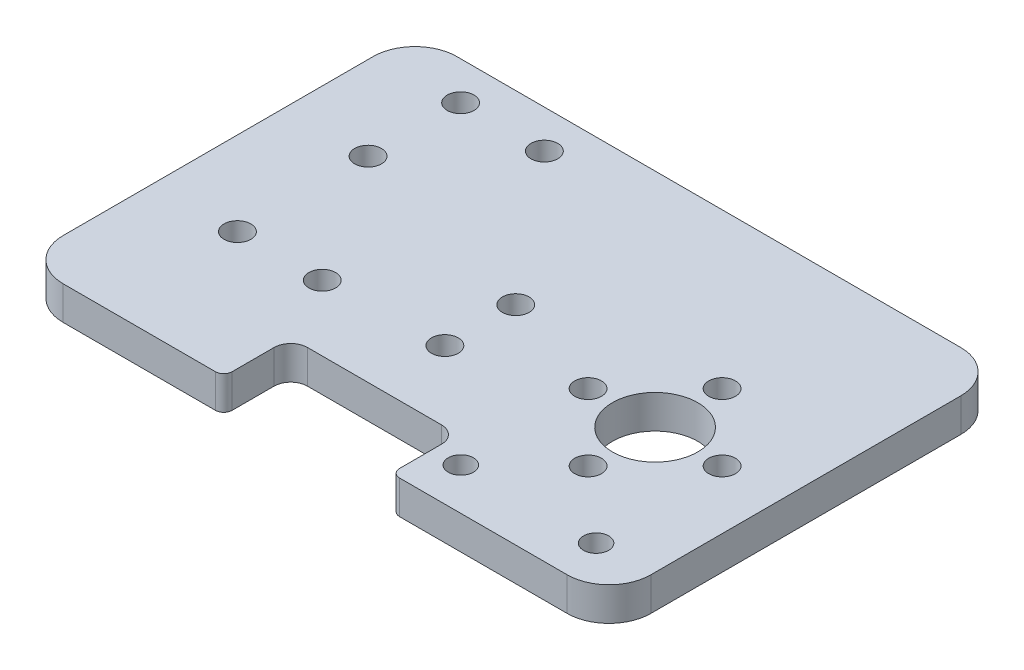
from build123d import *

# Parameters (mm, degrees)
SKETCH_1_W                = 180
SKETCH_1_H                = 43
EXTRUDE_335_DEPTH         = 4
SKETCH_2_R                = 5.1
SKETCH_2_R_2              = 1.6
CUT_EXTRUDE_616_DEPTH     = 5
SKETCH_10_W               = 20
SKETCH_10_H               = 43
CUT_EXTRUDE_3591_DEPTH    = 5
SKETCH_11_W               = 18
SKETCH_11_H               = 43
EXTRUDE_3904_DEPTH        = 4
SKETCH_12_W               = 40
SKETCH_12_H               = 13
CUT_EXTRUDE_3_DEPTH       = 10
SKETCH_14_R               = 1.6
CUT_EXTRUDE_4861_DEPTH    = 10
SKETCH_15_R               = 1.6
CUT_EXTRUDE_5298_DEPTH    = 5
PATTERN_LINEAR_5588_COUNT = 2
PATTERN_LINEAR_5588_PITCH = 29.8
CUT_EXTRUDE_6381_DEPTH    = 5
SKETCH_19_W               = 104
SKETCH_19_H               = 43
CUT_EXTRUDE_7034_DEPTH    = 5
FILLET_9_R                = 5
CUT_EXTRUDE_1_DEPTH       = 5
SKETCH_30_W               = 2
SKETCH_30_H               = 43
EXTRUDE_1_DEPTH           = 4
SKETCH_32_W               = 9
SKETCH_32_H               = 43
EXTRUDE_2_DEPTH           = 4
FILLET_11_R               = 5
EXTRUDE_3_DEPTH           = 4
FILLET_12_R               = 5
SKETCH_34_R               = 1.500000001
SKETCH_34_R_2             = 1.500000004
CUT_EXTRUDE_3_2_DEPTH     = 5
SKETCH_35_R               = 1.6
CUT_EXTRUDE_4_DEPTH       = 5
SKETCH_36_R               = 1.6
CUT_EXTRUDE_5_DEPTH       = 5
SKETCH_37_R               = 1.6
CUT_EXTRUDE_6_DEPTH       = 5
CUT_EXTRUDE_7_DEPTH       = 5
FILLET_15_R               = 1


with BuildPart() as part:
    # 草图1 → Extrude 335 (new body)
    with BuildSketch(Plane(origin=(0, 0, 0), x_dir=(1, 0, 0), z_dir=(0, 1, 0))):
        Rectangle(SKETCH_1_W, SKETCH_1_H)
    extrude(amount=EXTRUDE_335_DEPTH)

    # 草图2 → Cut-Extrude 616 (cut, through all)
    with BuildSketch(Plane(origin=(0, 4, 0), x_dir=(1, 0, 0), z_dir=(0, 1, 0))):
        with Locations((55, -5)):
            Circle(SKETCH_2_R)
        with Locations((63, -5)):
            Circle(SKETCH_2_R_2)
        with Locations((55, -13)):
            Circle(SKETCH_2_R_2)
        with Locations((47, -5)):
            Circle(SKETCH_2_R_2)
        with Locations((55, 3)):
            Circle(SKETCH_2_R_2)
    extrude(amount=-CUT_EXTRUDE_616_DEPTH, mode=Mode.SUBTRACT)

    # 草图10 → Cut-Extrude 3591 (cut, through all)
    with BuildSketch(Plane(origin=(0, 4, 0), x_dir=(1, 0, 0), z_dir=(0, 1, 0))):
        with Locations((80, 0)):
            Rectangle(SKETCH_10_W, SKETCH_10_H)
    extrude(amount=-CUT_EXTRUDE_3591_DEPTH, mode=Mode.SUBTRACT)

    # 草图11 → Extrude 3904 (add, through all)
    with BuildSketch(Plane(origin=(0, 4, 0), x_dir=(1, 0, 0), z_dir=(0, 1, 0))):
        with Locations((-99, 0)):
            Rectangle(SKETCH_11_W, SKETCH_11_H)
    extrude(amount=-EXTRUDE_3904_DEPTH)

    # 草图12 → Cut-Extrude 3 (cut)
    with BuildSketch(Plane(origin=(0, 4, 0), x_dir=(1, 0, 0), z_dir=(0, 1, 0))):
        with Locations((-88, -21.5)):
            Rectangle(SKETCH_12_W, SKETCH_12_H)
    extrude(amount=-CUT_EXTRUDE_3_DEPTH, mode=Mode.SUBTRACT)

    # 草图14 → Cut-Extrude 4861 (cut)
    with BuildSketch(Plane(origin=(0, 4, 0), x_dir=(1, 0, 0), z_dir=(0, 1, 0))):
        with Locations((46, -18.5)):
            Circle(SKETCH_14_R)
        with Locations((64, -18.5)):
            Circle(SKETCH_14_R)
    extrude(amount=-CUT_EXTRUDE_4861_DEPTH, mode=Mode.SUBTRACT)

    # 草图15 → Cut-Extrude 5298 (cut, through all)
    with BuildSketch(Plane(origin=(0, 4, 0), x_dir=(1, 0, 0), z_dir=(0, 1, 0))):
        with Locations((-102.9, 3.25)):
            Circle(SKETCH_15_R)
        with Locations((-73.1, 3.25)):
            Circle(SKETCH_15_R)
    extrude(amount=-CUT_EXTRUDE_5298_DEPTH, mode=Mode.SUBTRACT)

    # 草图16 → Cut-Revolve 5530 (revolve, cut)
    with BuildSketch(Plane.XY.offset(-3.25)):
        Polygon((-102.9, 0), (-99.7, 0), (-101.3, 1.6), (-102.9, 1.6), align=None)
    cut_revolve_5530 = revolve(axis=Axis((-102.9, -994.071718491, -3.25), (0, 1, 0)), mode=Mode.SUBTRACT)

    # Pattern Linear 5588: Cut-Revolve 5530 ×2
    with Locations(*[(i * PATTERN_LINEAR_5588_PITCH, 0, 0) for i in range(1, PATTERN_LINEAR_5588_COUNT)]):
        add(cut_revolve_5530, mode=Mode.SUBTRACT)

    # 草图17 → Cut-Extrude 6381 (cut, through all)
    with BuildSketch(Plane.XZ):
        with BuildLine():
            Line((-104.45, 3.75), (-101.35, 3.75))
            ThreePointArc((-101.35, 3.75), (-99.85, 5.25), (-101.35, 6.75))
            Line((-101.35, 6.75), (-101.35, 9.75))
            ThreePointArc((-101.35, 9.75), (-99.85, 11.25), (-101.35, 12.75))
            Line((-101.35, 12.75), (-104.45, 12.75))
            ThreePointArc((-104.45, 12.75), (-105.95, 11.25), (-104.45, 9.75))
            Line((-104.45, 9.75), (-104.45, 6.75))
            ThreePointArc((-104.45, 6.75), (-105.95, 5.25), (-104.45, 3.75))
        make_face()
        with BuildLine():
            Line((-104.45, -16.25), (-104.45, -13.25))
            ThreePointArc((-104.45, -13.25), (-105.95, -11.75), (-104.45, -10.25))
            Line((-104.45, -10.25), (-101.35, -10.25))
            ThreePointArc((-101.35, -10.25), (-99.85, -11.75), (-101.35, -13.25))
            Line((-101.35, -13.25), (-101.35, -16.25))
            ThreePointArc((-101.35, -16.25), (-99.85, -17.75), (-101.35, -19.25))
            Line((-101.35, -19.25), (-104.45, -19.25))
            ThreePointArc((-104.45, -19.25), (-105.95, -17.75), (-104.45, -16.25))
        make_face()
        with BuildLine():
            Line((-71.55, -16.25), (-71.55, -13.25))
            ThreePointArc((-71.55, -13.25), (-70.05, -11.75), (-71.55, -10.25))
            Line((-71.55, -10.25), (-74.65, -10.25))
            ThreePointArc((-74.65, -10.25), (-76.15, -11.75), (-74.65, -13.25))
            Line((-74.65, -13.25), (-74.65, -16.25))
            ThreePointArc((-74.65, -16.25), (-76.15, -17.75), (-74.65, -19.25))
            Line((-74.65, -19.25), (-71.55, -19.25))
            ThreePointArc((-71.55, -19.25), (-70.05, -17.75), (-71.55, -16.25))
        make_face()
        with BuildLine():
            Line((-71.55, 9.75), (-71.55, 6.75))
            ThreePointArc((-71.55, 6.75), (-70.05, 5.25), (-71.55, 3.75))
            Line((-71.55, 3.75), (-74.65, 3.75))
            ThreePointArc((-74.65, 3.75), (-76.15, 5.25), (-74.65, 6.75))
            Line((-74.65, 6.75), (-74.65, 9.75))
            ThreePointArc((-74.65, 9.75), (-76.15, 11.25), (-74.65, 12.75))
            Line((-74.65, 12.75), (-71.55, 12.75))
            ThreePointArc((-71.55, 12.75), (-70.05, 11.25), (-71.55, 9.75))
        make_face()
    extrude(amount=-CUT_EXTRUDE_6381_DEPTH, mode=Mode.SUBTRACT)

    # 草图19 → Cut-Extrude 7034 (cut, through all)
    with BuildSketch(Plane(origin=(0, 4, 0), x_dir=(1, 0, 0), z_dir=(0, 1, 0))):
        with Locations((-56, 0)):
            Rectangle(SKETCH_19_W, SKETCH_19_H)
    extrude(amount=-CUT_EXTRUDE_7034_DEPTH, mode=Mode.SUBTRACT)

    # 圆角9
    fillet_9_edges = [part.edges().sort_by_distance(p)[0] for p in [
        (-4, 2, 21.5),
        (-4, 2, -21.5),
        (70, 2, 21.5),
        (70, 2, -21.5),
    ]]
    fillet(fillet_9_edges, radius=FILLET_9_R)

    # 草图29 → Cut-Extrude 1 (cut, through all)
    with BuildSketch(Plane(origin=(0, 4, 0), x_dir=(1, 0, 0), z_dir=(0, 1, 0))):
        Polygon((1, 21.5), (10.830690118, 21.5), (10.830690118, -21.5), (1, -21.5), (-4.254253264, -21.5), (-4.254253264, 21.5), align=None)
    extrude(amount=-CUT_EXTRUDE_1_DEPTH, mode=Mode.SUBTRACT)

    # 草图30 → 凸台-拉伸1 (add)
    with BuildSketch(Plane(origin=(0, 4, 0), x_dir=(1, 0, 0), z_dir=(0, 1, 0))):
        with Locations((9.830690118, 0)):
            Rectangle(SKETCH_30_W, SKETCH_30_H)
    extrude(amount=-EXTRUDE_1_DEPTH)

    # 草图32 → Extrude 2 (add)
    with BuildSketch(Plane.XZ):
        with Locations((4.330690118, 0)):
            Rectangle(SKETCH_32_W, SKETCH_32_H)
    extrude(amount=-EXTRUDE_2_DEPTH)

    # 圆角11
    fillet_11_edges = [part.edges().sort_by_distance(p)[0] for p in [
        (-0.169309882, 2, -21.5),
        (-0.169309882, 2, 21.5),
    ]]
    fillet(fillet_11_edges, radius=FILLET_11_R)

    # 草图33 → 凸台-拉伸3 (add)
    with BuildSketch(Plane.XZ):
        Polygon((70, 16.5), (70, 25.500000005), (65, 25.500000005), (0, 25.500000005), (-0.169309882, 25.500000005), (-0.169309882, 16.5), align=None)
    extrude(amount=-EXTRUDE_3_DEPTH)

    # 圆角12
    fillet_12_edges = [part.edges().sort_by_distance(p)[0] for p in [
        (-0.169309882, 2, 25.500000005),
        (70, 2, 25.500000005),
    ]]
    fillet(fillet_12_edges, radius=FILLET_12_R)

    # 草图34 → Cut-Extrude 3 2 (cut, through all)
    with BuildSketch(Plane.XZ):
        with Locations((63.455393867, 20.5)):
            Circle(SKETCH_34_R)
        with Locations((47.301465353, 20.5)):
            Circle(SKETCH_34_R_2)
    extrude(amount=-CUT_EXTRUDE_3_2_DEPTH, mode=Mode.SUBTRACT)

    # 草图35 → 切除-拉伸4 (cut, through all)
    with BuildSketch(Plane.XZ):
        with Locations((34, 0.636740591)):
            Circle(SKETCH_35_R)
        with Locations((34, 9.1)):
            Circle(SKETCH_35_R)
    extrude(amount=-CUT_EXTRUDE_4_DEPTH, mode=Mode.SUBTRACT)

    # 草图36 → 切除-拉伸5 (cut, through all)
    with BuildSketch(Plane.XZ):
        with Locations((9.830690118, -5.9)):
            Circle(SKETCH_36_R)
        with Locations((9.830690118, 9.7)):
            Circle(SKETCH_36_R)
        with Locations((9.830690118, -16.948915218)):
            Circle(SKETCH_36_R)
        with Locations((19.830690118, -16.948915218)):
            Circle(SKETCH_36_R)
    extrude(amount=-CUT_EXTRUDE_5_DEPTH, mode=Mode.SUBTRACT)

    # 草图37 → 切除-拉伸6 (cut, through all)
    with BuildSketch(Plane(origin=(0, 4, 0), x_dir=(1, 0, 0), z_dir=(0, 1, 0))):
        with Locations((19.925091374, -9.664193429)):
            Circle(SKETCH_37_R)
    extrude(amount=-CUT_EXTRUDE_6_DEPTH, mode=Mode.SUBTRACT)

    # 草图38 → 切除-拉伸7 (cut, through all)
    with BuildSketch(Plane.XZ):
        with BuildLine():
            Line((44, 25.500000005), (44, 19.500000005))
            ThreePointArc((44, 19.500000005), (43.414213562, 18.085786442), (42, 17.500000005))
            Line((42, 17.500000005), (26, 17.500000005))
            ThreePointArc((26, 17.500000005), (24.585786438, 18.085786442), (24, 19.500000005))
            Line((24, 19.500000005), (24, 25.500000005))
            Line((24, 25.500000005), (44, 25.500000005))
        make_face()
    extrude(amount=-CUT_EXTRUDE_7_DEPTH, mode=Mode.SUBTRACT)

    # 圆角15
    fillet_15_edges = [part.edges().sort_by_distance(p)[0] for p in [
        (24, 2, 25.500000005),
        (44, 2, 25.500000005),
    ]]
    fillet(fillet_15_edges, radius=FILLET_15_R)


solid = part.part
